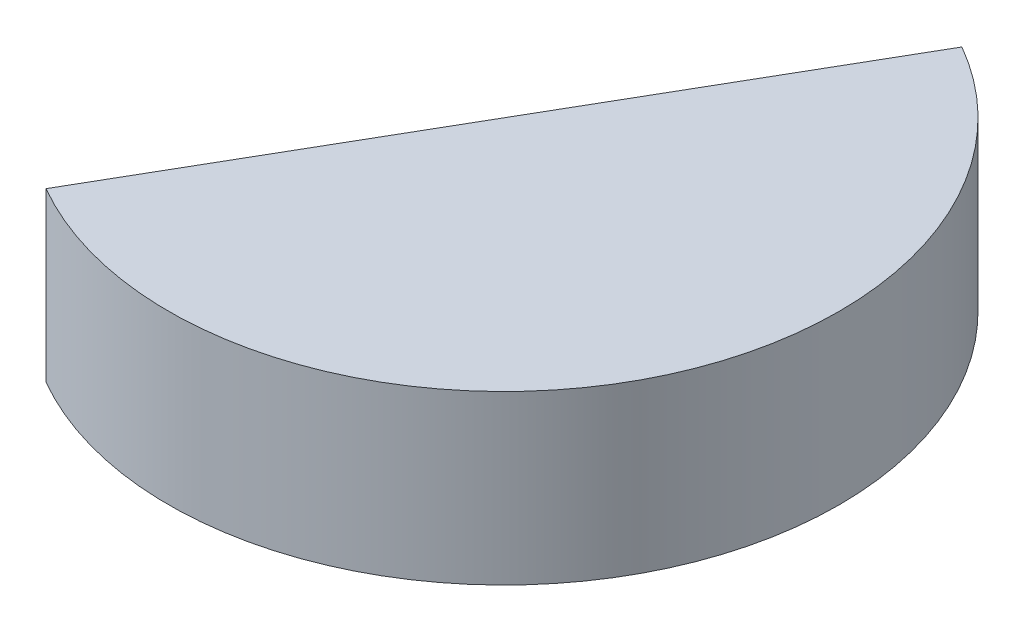
from build123d import *

# Parameters (mm, degrees)
SKETCH5_W               = 10000
SKETCH5_H               = 5000
REVOLVE1_ANGLE          = 330
CUT_EXTRUDE1_DEPTH      = 1
CUT_EXTRUDE1_DEPTH_BACK = 5001


with BuildPart() as part:
    # Sketch5 → Revolve1 (revolve)
    with BuildSketch(Plane(origin=(0, 0, 0), x_dir=(0, 0, -1), z_dir=(1, 0, 0))):
        with Locations((5000, 2500)):
            Rectangle(SKETCH5_W, SKETCH5_H)
    revolve(axis=Axis((0, 0, 0), (0, 1, 0)), revolution_arc=REVOLVE1_ANGLE)

    # Sketch6 → Cut-Extrude1 (cut, two sides)
    with BuildSketch(Plane(origin=(0, 5000, 0), x_dir=(1, 0, 0), z_dir=(0, 1, 0))) as cut_extrude1_sk:
        Polygon((0, 0), (-6270.925142449, -10861.560957183), (-18667.396460838, 4058.560061627), (972.453773693, 11788.52125661), align=None)
    extrude(amount=CUT_EXTRUDE1_DEPTH, mode=Mode.SUBTRACT)
    extrude(cut_extrude1_sk.sketch, amount=-CUT_EXTRUDE1_DEPTH_BACK, mode=Mode.SUBTRACT)


solid = part.part
